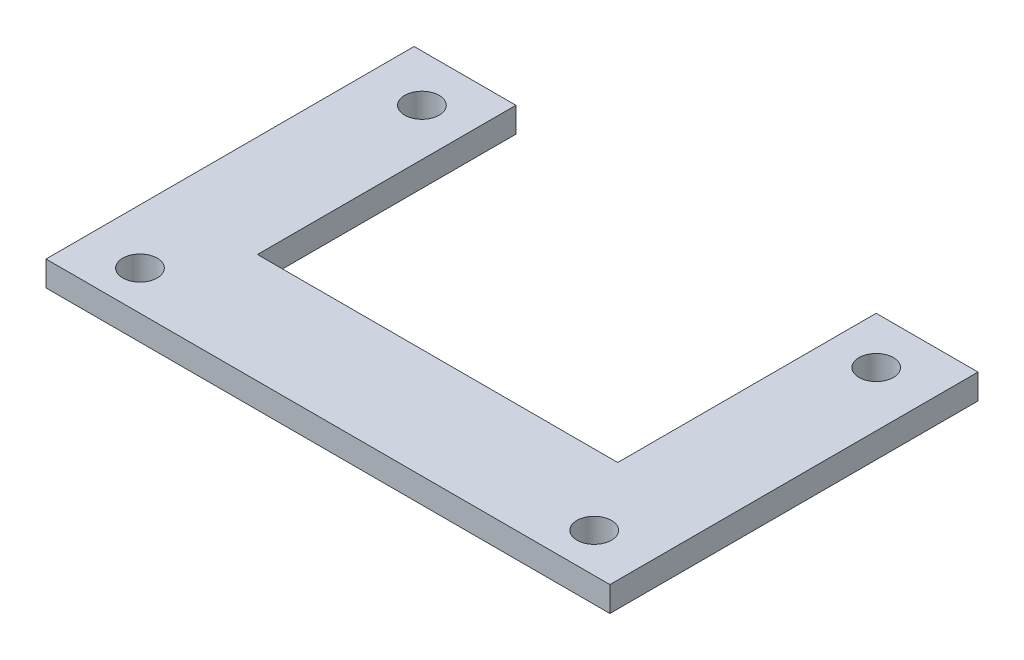
from build123d import *

# Parameters (mm, degrees)
SKETCH_1_W          = 36
SKETCH_1_H          = 24
EXTRUDE_3_DEPTH     = 1.6
SKETCH_3_W          = 22
SKETCH_3_H          = 16
CUT_EXTRUDE_1_DEPTH = 1.6
SKETCH_4_R          = 1.1
CUT_EXTRUDE_2_DEPTH = 1.6
CUT_EXTRUDE_3_DEPTH = 3
SKETCH_6_W          = 36
SKETCH_6_H          = 0.5
CUT_EXTRUDE_4_DEPTH = 3


with BuildPart() as part:
    # 草图1 → 凸台-拉伸3 (new body)
    with BuildSketch(Plane(origin=(0, 0, 0), x_dir=(1, 0, 0), z_dir=(0, 1, 0))):
        with Locations((18, -12)):
            Rectangle(SKETCH_1_W, SKETCH_1_H)
    extrude(amount=EXTRUDE_3_DEPTH)

    # 草图3 → 切除-拉伸1 (cut)
    with BuildSketch(Plane(origin=(0, 1.6, 0), x_dir=(1, 0, 0), z_dir=(0, 1, 0))):
        with Locations((18, -8)):
            Rectangle(SKETCH_3_W, SKETCH_3_H)
    extrude(amount=-CUT_EXTRUDE_1_DEPTH, mode=Mode.SUBTRACT)

    # 草图4 → 切除-拉伸2 (cut)
    with BuildSketch(Plane(origin=(0, 1.6, 0), x_dir=(1, 0, 0), z_dir=(0, 1, 0))):
        with Locations((3.5, -3)):
            Circle(SKETCH_4_R)
        with Locations((32.5, -3)):
            Circle(SKETCH_4_R)
        with Locations((3.5, -21)):
            Circle(SKETCH_4_R)
        with Locations((32.5, -21)):
            Circle(SKETCH_4_R)
    extrude(amount=-CUT_EXTRUDE_2_DEPTH, mode=Mode.SUBTRACT)

    # 草图5 → 切除-拉伸3 (cut)
    with BuildSketch(Plane(origin=(0, 1.6, 0), x_dir=(1, 0, 0), z_dir=(0, 1, 0))):
        Polygon((7, 0), (6.5, 0), (6.5, -16.5), (29.5, -16.5), (29.5, 0), (29, 0), (29, -16), (7, -16), align=None)
    extrude(amount=-CUT_EXTRUDE_3_DEPTH, mode=Mode.SUBTRACT)

    # 草图6 → 切除-拉伸4 (cut)
    with BuildSketch(Plane(origin=(0, 1.6, 0), x_dir=(1, 0, 0), z_dir=(0, 1, 0))):
        with Locations((18, -23.75)):
            Rectangle(SKETCH_6_W, SKETCH_6_H)
    extrude(amount=-CUT_EXTRUDE_4_DEPTH, mode=Mode.SUBTRACT)


solid = part.part
